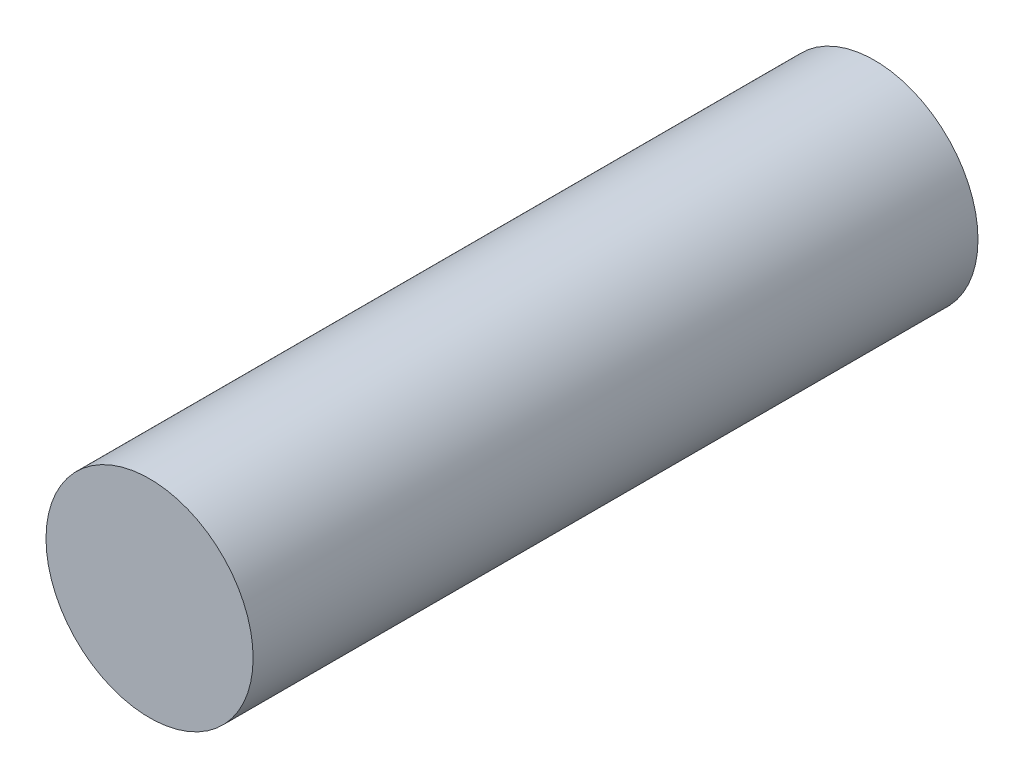
from build123d import *

# Parameters (mm, degrees)
SKETCH2_R           = 5
BOSS_EXTRUDE1_DEPTH = 35


with BuildPart() as part:
    # Sketch2 → Boss-Extrude1 (new body)
    with BuildSketch(Plane.XY):
        Circle(SKETCH2_R)
    extrude(amount=BOSS_EXTRUDE1_DEPTH)


solid = part.part
